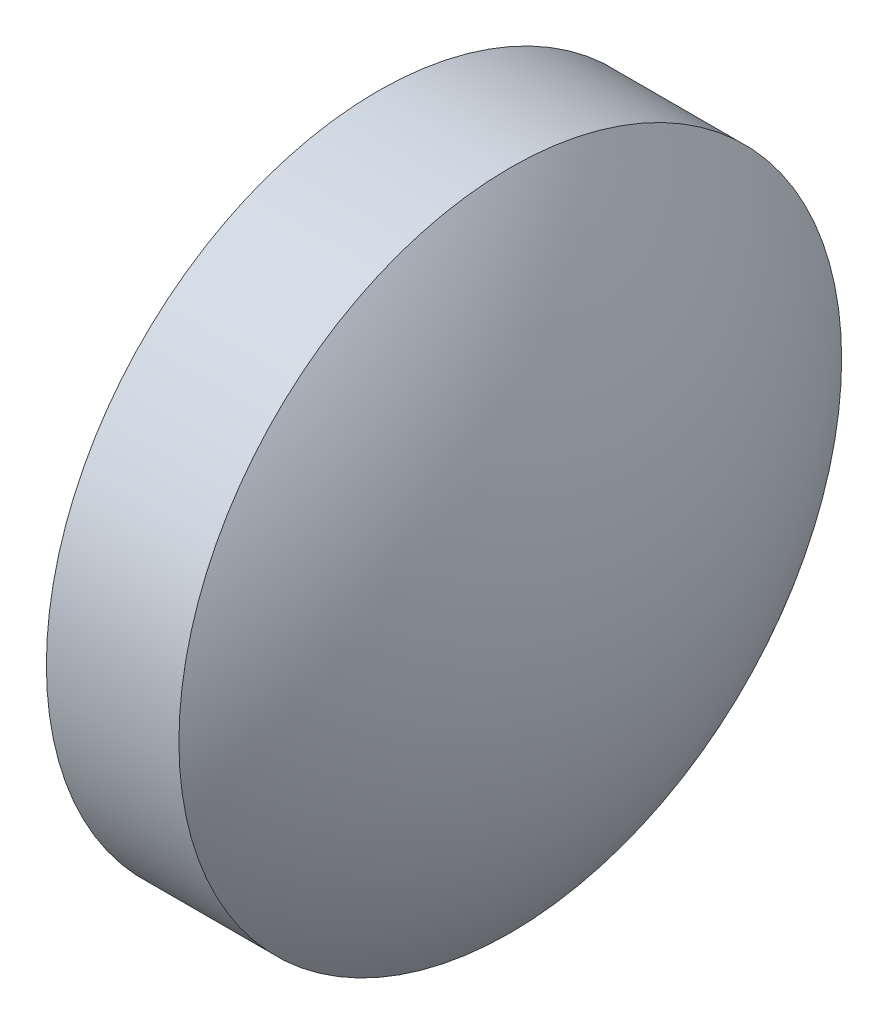
from build123d import *

# Parameters (mm, degrees)
SKETCH_1_ONE_SIDE_W = 1
SKETCH_1_ONE_SIDE_H = 2.5


with BuildPart() as part:
    # 草图1 one side → 旋转1 (revolve)
    with BuildSketch(Plane.XY):
        with Locations((17.019329483, 10.820100989)):
            Rectangle(SKETCH_1_ONE_SIDE_W, SKETCH_1_ONE_SIDE_H)
        with BuildLine():
            Line((15.694722069, 9.570100989), (16.519329483, 9.570100989))
            Line((16.519329483, 9.570100989), (16.519329483, 12.070100989))
            ThreePointArc((16.519329483, 12.070100989), (15.906195328, 10.8863435), (15.694722069, 9.570100989))
        make_face()
        with BuildLine():
            Line((17.519329483, 9.570100989), (18.343936898, 9.570100989))
            ThreePointArc((18.343936898, 9.570100989), (18.132463639, 10.8863435), (17.519329483, 12.070100989))
            Line((17.519329483, 12.070100989), (17.519329483, 9.570100989))
        make_face()
    revolve(axis=Axis((15.236180101, 9.570100989, 0), (1, 0, 0)))


solid = part.part
